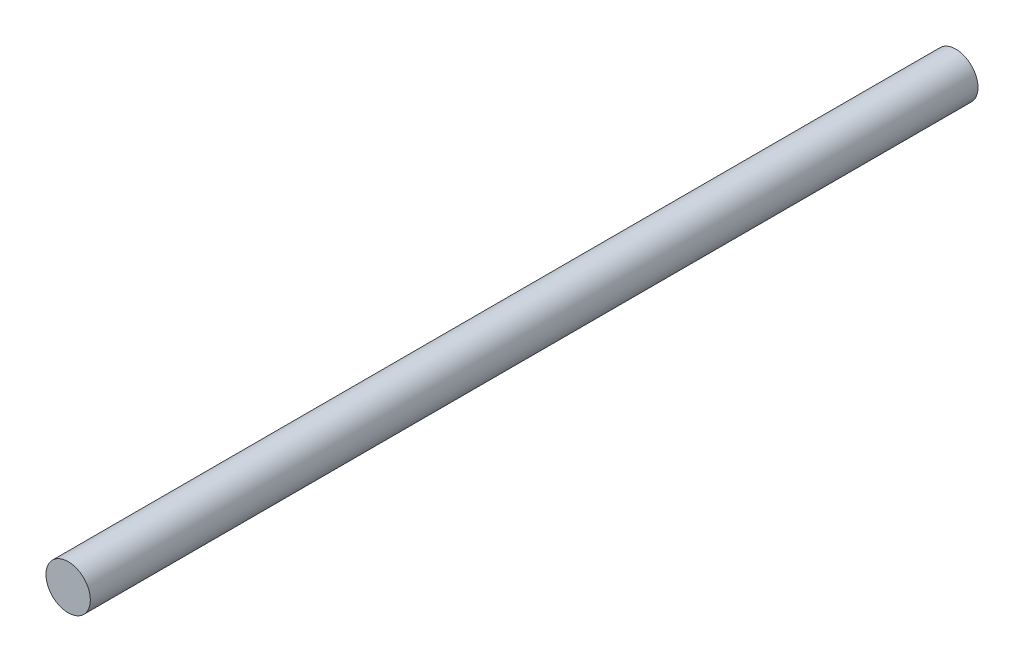
from build123d import *

# Parameters (mm, degrees)
SKETCH_1_R      = 1.5
EXTRUDE_1_DEPTH = 60


with BuildPart() as part:
    # 草图1 → 凸台-拉伸1 (new body)
    with BuildSketch(Plane.XY):
        Circle(SKETCH_1_R)
    extrude(amount=EXTRUDE_1_DEPTH)


solid = part.part
